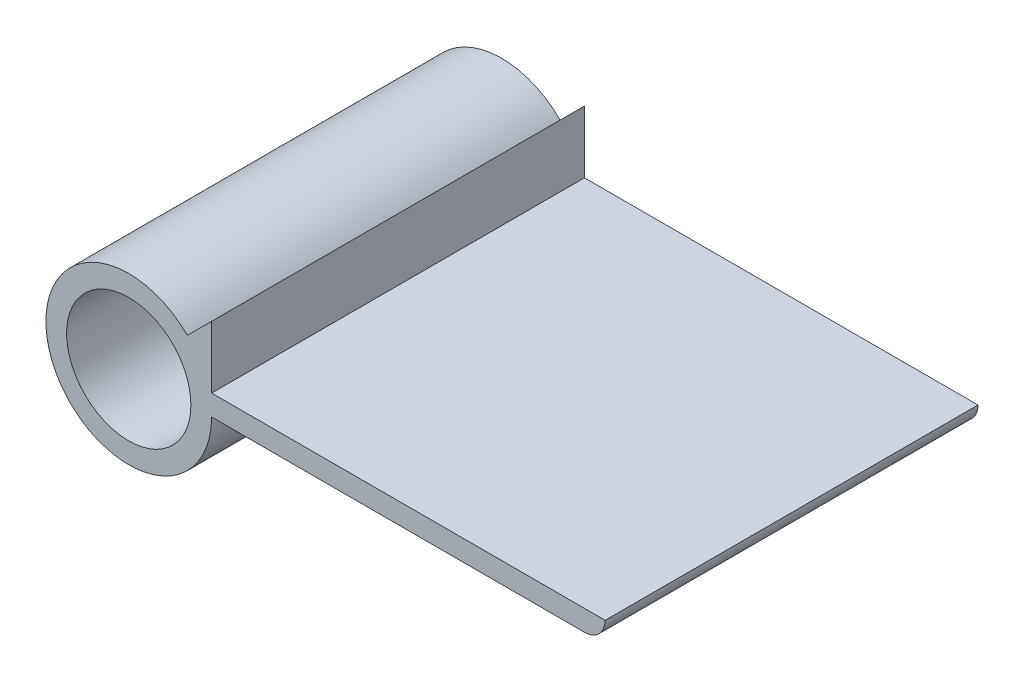
from build123d import *

# Parameters (mm, degrees)
SKETCH2_R           = 6
BOSS_EXTRUDE2_DEPTH = 36


with BuildPart() as part:
    # Sketch2 → Boss-Extrude2 (new body)
    with BuildSketch(Plane.XY):
        with BuildLine():
            Line((46, 2), (8, 2))
            Line((8, 2), (8, 8))
            Line((8, 8), (5.656854249, 5.656854249))
            ThreePointArc((5.656854249, 5.656854249), (-7.39103626, -3.061467459), (8, 0))
            Line((8, 0), (44, 0))
            ThreePointArc((44, 0), (45.414213562, 0.585786438), (46, 2))
        make_face()
        Circle(SKETCH2_R, mode=Mode.SUBTRACT)
    extrude(amount=BOSS_EXTRUDE2_DEPTH)


solid = part.part
